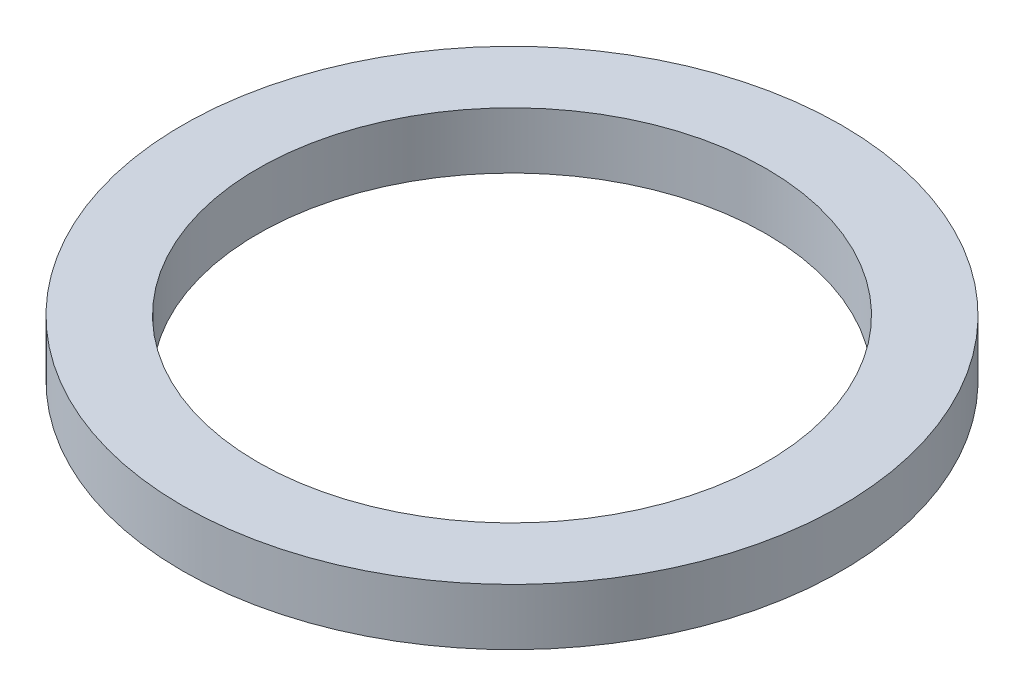
from build123d import *

# Parameters (mm, degrees)
SKETCH1_R           = 4.445
SKETCH1_R_2         = 3.429
BOSS_EXTRUDE1_DEPTH = 0.762


with BuildPart() as part:
    # Sketch1 → Boss-Extrude1 (new body)
    with BuildSketch(Plane(origin=(0, 0, 0), x_dir=(1, 0, 0), z_dir=(0, 1, 0))):
        Circle(SKETCH1_R)
        Circle(SKETCH1_R_2, mode=Mode.SUBTRACT)
    extrude(amount=BOSS_EXTRUDE1_DEPTH)


solid = part.part
